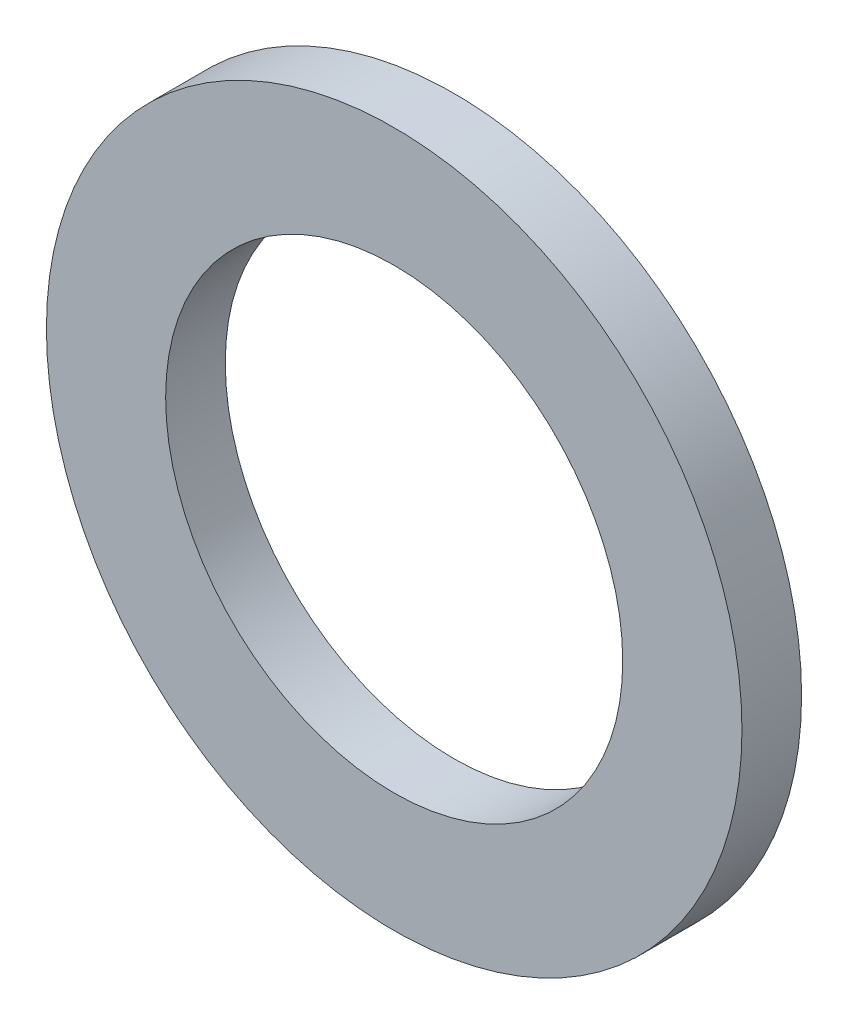
from build123d import *

# Parameters (mm, degrees)
SKETCH1_R           = 17.5
SKETCH1_R_2         = 11.5
BOSS_EXTRUDE1_DEPTH = 3


with BuildPart() as part:
    # Sketch1 → Boss-Extrude1 (new body)
    with BuildSketch(Plane.XY):
        Circle(SKETCH1_R)
        Circle(SKETCH1_R_2, mode=Mode.SUBTRACT)
    extrude(amount=BOSS_EXTRUDE1_DEPTH)


solid = part.part
